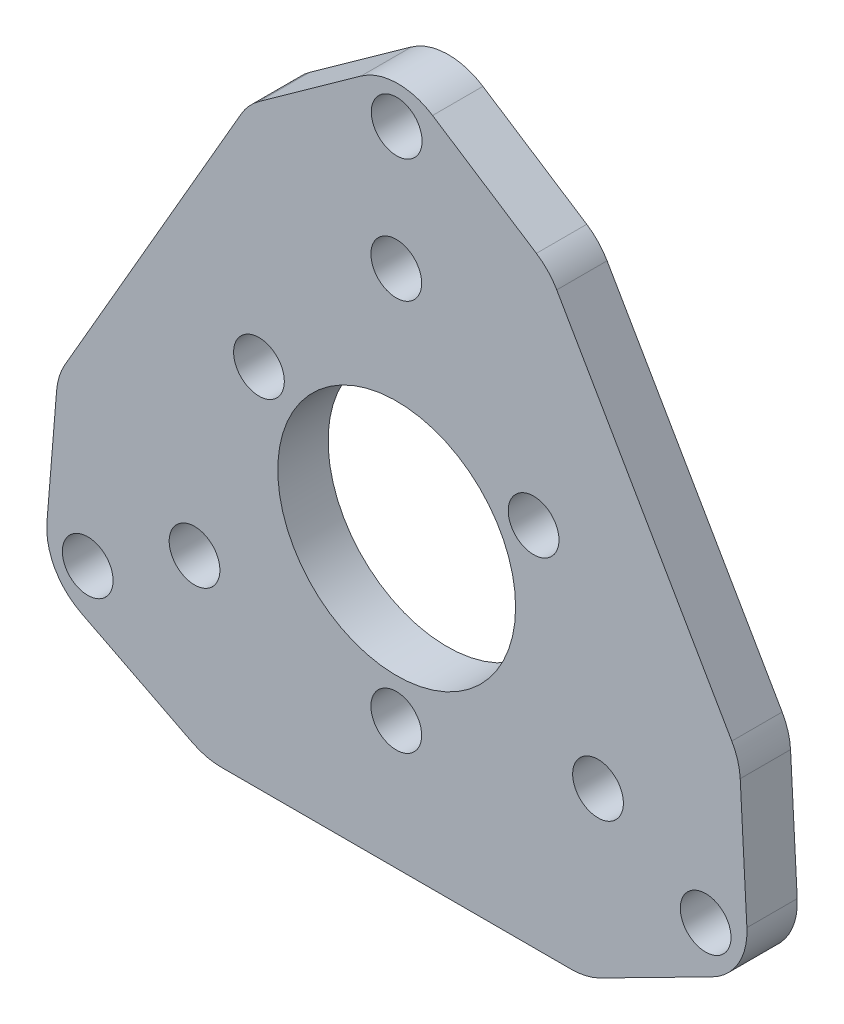
from build123d import *

# Parameters (mm, degrees)
SKETCH1_R           = 1.6
BOSS_EXTRUDE1_DEPTH = 3.175
SKETCH2_R           = 1.6
SKETCH2_R_2         = 7.5
CUT_EXTRUDE1_DEPTH  = 4.175
BOSS_EXTRUDE3_DEPTH = 3.175


with BuildPart() as part:
    # Sketch1 → Boss-Extrude1 (new body)
    with BuildSketch(Plane.XY):
        with BuildLine():
            Line((31.086717458, 32.79124845), (24.539210672, 37.049362302))
            ThreePointArc((24.539210672, 37.049362302), (22.268882249, 37.695107847), (20.029743315, 36.948358029))
            Line((20.029743315, 36.948358029), (13.602836128, 32.346493758))
            ThreePointArc((13.602836128, 32.346493758), (12.968237383, 31.781029757), (12.467444066, 31.094246563))
            Line((12.467444066, 31.094246563), (1.349560594, 11.837507517))
            ThreePointArc((1.349560594, 11.837507517), (0.995156132, 11.028730142), (0.826837821, 10.16190126))
            Line((0.826837821, 10.16190126), (0.217529035, 2.673448792))
            ThreePointArc((0.217529035, 2.673448792), (0.712425098, 0.398045931), (2.390731369, -1.216162343))
            Line((2.390731369, -1.216162343), (9.39530455, -4.779380795))
            ThreePointArc((9.39530455, -4.779380795), (10.276421795, -5.10394936), (11.208926603, -5.214163404))
            Line((11.208926603, -5.214163404), (33.291073397, -5.214163404))
            ThreePointArc((33.291073397, -5.214163404), (34.223578205, -5.10394936), (35.10469545, -4.779380795))
            Line((35.10469545, -4.779380795), (42.181392008, -1.179473262))
            ThreePointArc((42.181392008, -1.179473262), (43.83187157, 0.385744129), (44.362149812, 2.597710054))
            Line((44.362149812, 2.597710054), (43.941412908, 10.526262814))
            ThreePointArc((43.941412908, 10.526262814), (43.781938908, 11.451617014), (43.411134666, 12.314296889))
            Line((43.411134666, 12.314296889), (32.370061269, 31.437996983))
            ThreePointArc((32.370061269, 31.437996983), (31.808360702, 32.190462814), (31.086717458, 32.79124845))
        make_face()
        with Locations((13.589745962, 17.846043489)):
            Circle(SKETCH1_R, mode=Mode.SUBTRACT)
        with Locations((9.526279442, 5.5)):
            Circle(SKETCH1_R, mode=Mode.SUBTRACT)
        with Locations((34.973720558, 5.5)):
            Circle(SKETCH1_R, mode=Mode.SUBTRACT)
        with Locations((30.910254038, 17.846043489)):
            Circle(SKETCH1_R, mode=Mode.SUBTRACT)
        with Locations((22.25, 27.538130468)):
            Circle(SKETCH1_R, mode=Mode.SUBTRACT)
        with Locations((22.25, 2.846043489)):
            Circle(SKETCH1_R, mode=Mode.SUBTRACT)
        with BuildLine():
            Line((42.370834875, 9.312177826), (35.370834875, -2.812177826))
            ThreePointArc((35.370834875, -2.812177826), (34.687822174, -2.995190528), (34.504809472, -2.312177826))
            Line((34.504809472, -2.312177826), (41.504809472, 9.812177826))
            ThreePointArc((41.504809472, 9.812177826), (42.187822174, 9.995190528), (42.370834875, 9.312177826))
        make_face(mode=Mode.SUBTRACT)
        with BuildLine():
            Line((10.01754221, -2.349929674), (3.01754221, 9.774425979))
            ThreePointArc((3.01754221, 9.774425979), (2.334529508, 9.957438681), (2.151516806, 9.274425979))
            Line((2.151516806, 9.274425979), (9.151516806, -2.849929674))
            ThreePointArc((9.151516806, -2.849929674), (9.834529508, -3.032942376), (10.01754221, -2.349929674))
        make_face(mode=Mode.SUBTRACT)
        with BuildLine():
            Line((15.358452868, 31.038130468), (29.358452868, 31.038130468))
            ThreePointArc((29.358452868, 31.038130468), (29.858452868, 31.538130468), (29.358452868, 32.038130468))
            Line((29.358452868, 32.038130468), (15.358452868, 32.038130468))
            ThreePointArc((15.358452868, 32.038130468), (14.858452868, 31.538130468), (15.358452868, 31.038130468))
        make_face(mode=Mode.SUBTRACT)
    extrude(amount=BOSS_EXTRUDE1_DEPTH)

    # Sketch2 → Cut-Extrude1 (cut, through all)
    with BuildSketch(Plane.XY.offset(3.175)):
        with Locations((41.761034996, 1.563830145)):
            Circle(SKETCH2_R)
        with Locations((2.789891826, 1.563830145)):
            Circle(SKETCH2_R)
        with Locations((22.275463411, 12.813830145)):
            Circle(SKETCH2_R_2)
        with Locations((22.275463411, 35.313830145)):
            Circle(SKETCH2_R)
    extrude(amount=-CUT_EXTRUDE1_DEPTH, mode=Mode.SUBTRACT)

    # Sketch3 → Boss-Extrude3 (add)
    with BuildSketch(Plane.XY.offset(3.175)):
        with BuildLine():
            Line((42.370834875, 9.312177826), (35.370834875, -2.812177826))
            ThreePointArc((35.370834875, -2.812177826), (34.687822174, -2.995190528), (34.504809472, -2.312177826))
            Line((34.504809472, -2.312177826), (41.504809472, 9.812177826))
            ThreePointArc((41.504809472, 9.812177826), (42.187822174, 9.995190528), (42.370834875, 9.312177826))
        make_face()
        with BuildLine():
            Line((10.01754221, -2.349929674), (3.01754221, 9.774425979))
            ThreePointArc((3.01754221, 9.774425979), (2.334529508, 9.957438681), (2.151516806, 9.274425979))
            Line((2.151516806, 9.274425979), (9.151516806, -2.849929674))
            ThreePointArc((9.151516806, -2.849929674), (9.834529508, -3.032942376), (10.01754221, -2.349929674))
        make_face()
        with BuildLine():
            Line((15.358452868, 31.038130468), (29.358452868, 31.038130468))
            ThreePointArc((29.358452868, 31.038130468), (29.858452868, 31.538130468), (29.358452868, 32.038130468))
            Line((29.358452868, 32.038130468), (15.358452868, 32.038130468))
            ThreePointArc((15.358452868, 32.038130468), (14.858452868, 31.538130468), (15.358452868, 31.038130468))
        make_face()
    extrude(amount=-BOSS_EXTRUDE3_DEPTH)


solid = part.part
